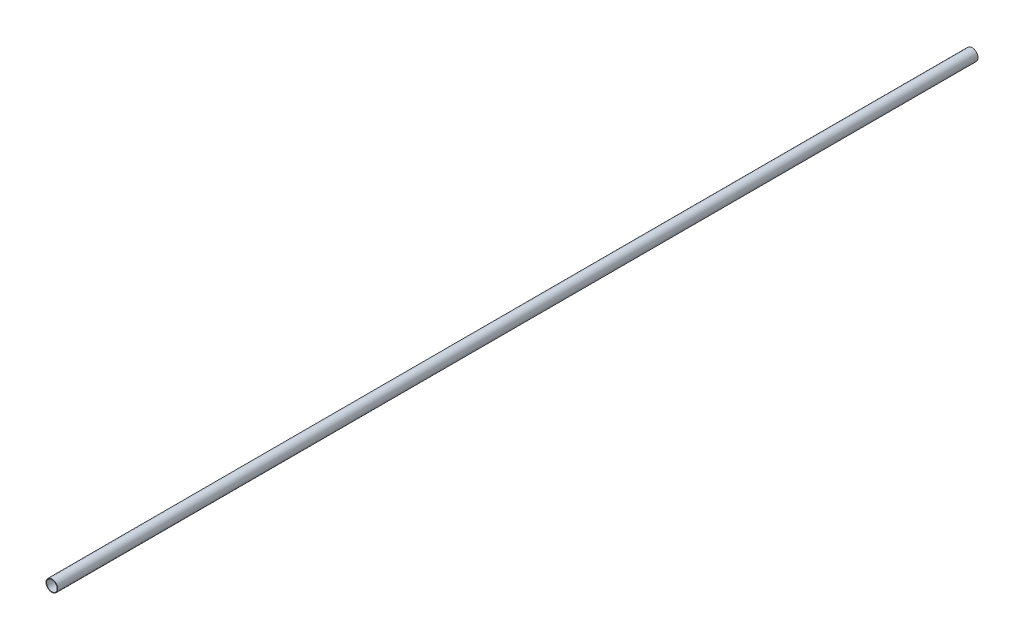
from build123d import *

# Parameters (mm, degrees)
SKETCH_1_R      = 5
SKETCH_1_R_2    = 4.5
EXTRUDE_1_DEPTH = 392


with BuildPart() as part:
    # Эскиз1 → Бобышка-Вытянуть1 (new body, symmetric)
    with BuildSketch(Plane.XY):
        Circle(SKETCH_1_R)
        Circle(SKETCH_1_R_2, mode=Mode.SUBTRACT)
    extrude(amount=EXTRUDE_1_DEPTH, both=True)


solid = part.part
